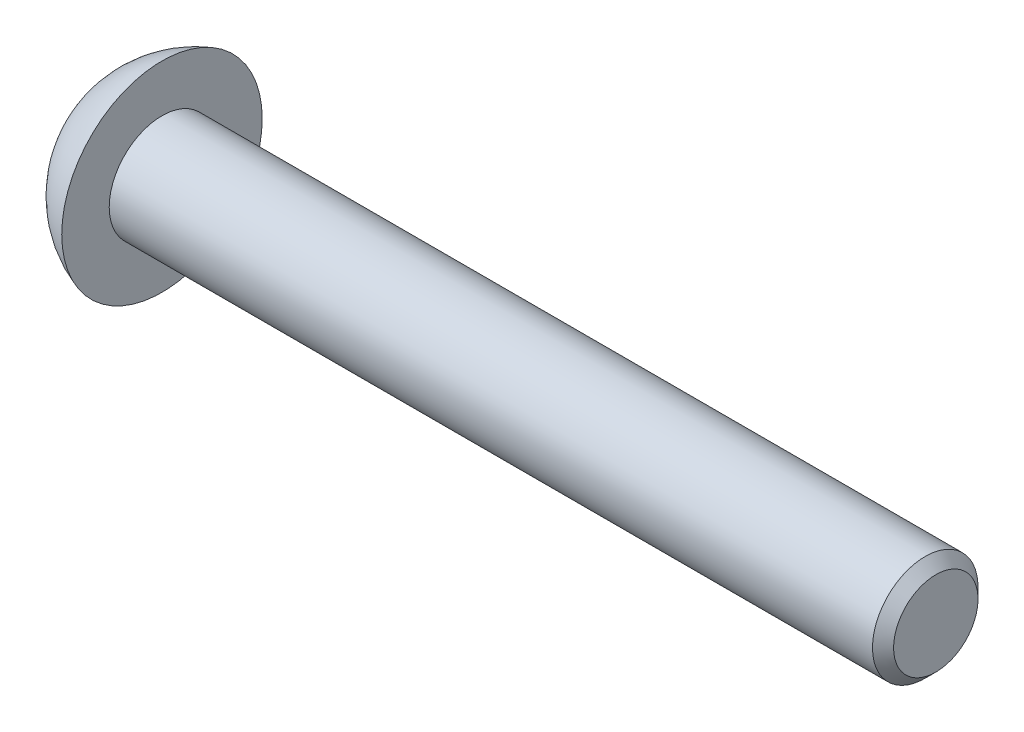
from build123d import *

# Parameters (mm, degrees)
CHAMFER1_SIZE      = 0.3
CUT_EXTRUDE1_DEPTH = 1.2


with BuildPart() as part:
    # Sketch1 → Revolve1 (revolve)
    with BuildSketch(Plane(origin=(0, 0, 0), x_dir=(1, 0, 0), z_dir=(0, 1, 0))):
        with BuildLine():
            ThreePointArc((3.937869631, 1.510997792), (3.937864578, 1.505498886), (3.937849421, 1.5))
            Line((3.937849421, 1.5), (22, 1.5))
            Line((22, 1.5), (22, 3))
            Line((22, 3), (3.541094523, 3))
            ThreePointArc((3.541094523, 3), (3.836974876, 2.281477847), (3.937869631, 1.510997792))
        make_face()
        with BuildLine():
            Line((0, 3), (0, 1.5))
            Line((0, 1.5), (3.937849421, 1.5))
            ThreePointArc((3.937849421, 1.5), (3.937864578, 1.505498886), (3.937869631, 1.510997792))
            ThreePointArc((3.937869631, 1.510997792), (3.836974876, 2.281477847), (3.541094523, 3))
            Line((3.541094523, 3), (0, 3))
        make_face()
        with BuildLine():
            Line((-1.65, 1.5), (0, 1.5))
            Line((0, 1.5), (0, 3))
            Line((0, 3), (0, 4.35))
            ThreePointArc((0, 4.35), (-0.949304344, 3.826927531), (-1.65, 3))
            Line((-1.65, 3), (-1.65, 2.5))
            Line((-1.65, 2.5), (-1.65, 1.5))
        make_face()
    revolve(axis=Axis((0, 0, -1.5), (1, 0, 0)))

    # Chamfer1
    chamfer1_edges = [part.edges().sort_by_distance(p)[0] for p in [
        (22, 0, 0),
    ]]
    chamfer(chamfer1_edges, length=CHAMFER1_SIZE)

    # Sketch2 → Cut-Extrude1 (cut)
    with BuildSketch(Plane.ZY.offset(1.65)):
        Polygon((-0.345299462, 0), (-0.922649731, 1), (-2.077350269, 1), (-2.654700538, 0), (-2.077350269, -1), (-0.922649731, -1), align=None)
    extrude(amount=-CUT_EXTRUDE1_DEPTH, mode=Mode.SUBTRACT)


solid = part.part
